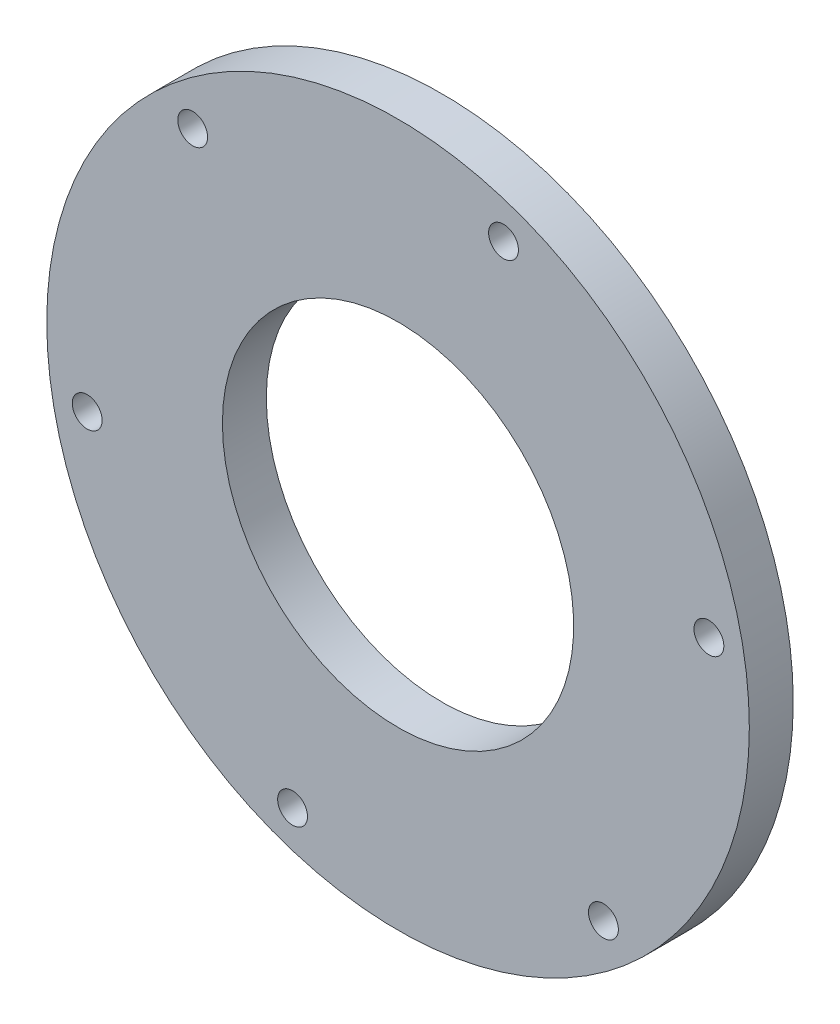
from build123d import *

# Parameters (mm, degrees)
SKETCH1_R           = 40
BOSS_EXTRUDE1_DEPTH = 5
SKETCH2_R           = 20
CUT_EXTRUDE1_DEPTH  = 6
SKETCH3_R           = 1.7
CUT_EXTRUDE2_DEPTH  = 6


with BuildPart() as part:
    # Sketch1 → Boss-Extrude1 (new body)
    with BuildSketch(Plane.XY):
        Circle(SKETCH1_R)
    extrude(amount=BOSS_EXTRUDE1_DEPTH)

    # Sketch2 → Cut-Extrude1 (cut, through all)
    with BuildSketch(Plane(origin=(0, 0, 0), x_dir=(-1, 0, 0), z_dir=(0, 0, -1))):
        Circle(SKETCH2_R)
    extrude(amount=-CUT_EXTRUDE1_DEPTH, mode=Mode.SUBTRACT)

    # Sketch3 → Cut-Extrude2 (cut, through all)
    with BuildSketch(Plane.XY.offset(5)):
        with Locations((12.009212016, 33.937867151)):
            Circle(SKETCH3_R)
        with Locations((35.395661111, 6.56865089)):
            Circle(SKETCH3_R)
        with Locations((23.386449095, -27.369216261)):
            Circle(SKETCH3_R)
        with Locations((-12.009212016, -33.937867151)):
            Circle(SKETCH3_R)
        with Locations((-35.395661111, -6.56865089)):
            Circle(SKETCH3_R)
        with Locations((-23.386449095, 27.369216261)):
            Circle(SKETCH3_R)
    extrude(amount=-CUT_EXTRUDE2_DEPTH, mode=Mode.SUBTRACT)


solid = part.part
